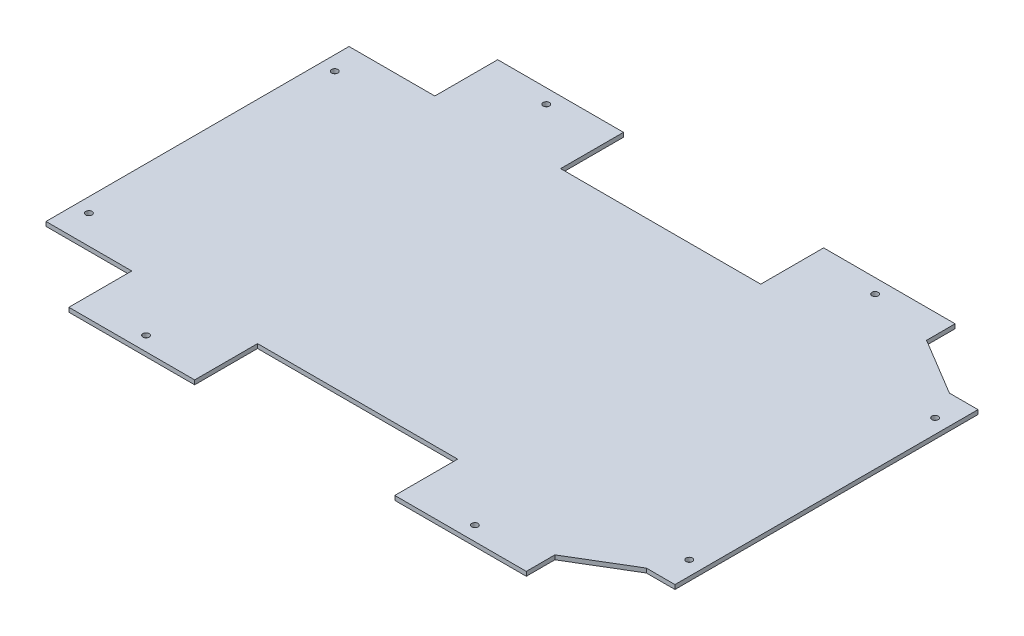
from build123d import *

# Parameters (mm, degrees)
BOSS_EXTRU_1_DEPTH   = 3
D_GAGEMENT_M41_D     = 4.4
D_GAGEMENT_M41_DEPTH = 5


with BuildPart() as part:
    # Esquisse4 → Boss.-Extru.1 (new body)
    with BuildSketch(Plane(origin=(0, 0, 0), x_dir=(1, 0, 0), z_dir=(0, 1, 0))):
        Polygon((197.809683941, 105.737894452), (157.80968394, 129.737894452), (157.80968394, 149.737894452), (65.80968453, 149.737894452), (65.80968453, 105.737894452), (-74.19031547, 105.737894452), (-74.19031547, 149.737894452), (-162.1903155, 149.737894452), (-162.1903155, 105.737894452), (-222.1903155, 105.737894452), (-222.1903155, -106.262104989), (-162.1903155, -106.262104989), (-162.1903155, -150.262104989), (-74.19031547, -150.262104989), (-74.19031547, -106.262104989), (65.80968453, -106.262104989), (65.80968453, -150.262104989), (157.80968394, -150.262104989), (157.80968394, -130.262104989), (197.809683941, -106.262104989), (217.809683941, -106.262104989), (217.809683941, 105.737894452), align=None)
    extrude(amount=BOSS_EXTRU_1_DEPTH)

    # Dégagement M41
    with Locations(Plane(origin=(0, 0, 0), x_dir=(-1, 0, 0), z_dir=(0, -1, 0))):
        with Locations((-207.809683941, 85.737894452), (-207.809683941, -86.262104989), (-111.809684235, -140.262104989), (118.190315485, -140.262104989), (-111.809684235, 139.737894452), (118.190315485, 139.737894452), (212.1903155, 85.737894452), (212.1903155, -86.262104989)):
            Hole(D_GAGEMENT_M41_D / 2, depth=D_GAGEMENT_M41_DEPTH)


solid = part.part
